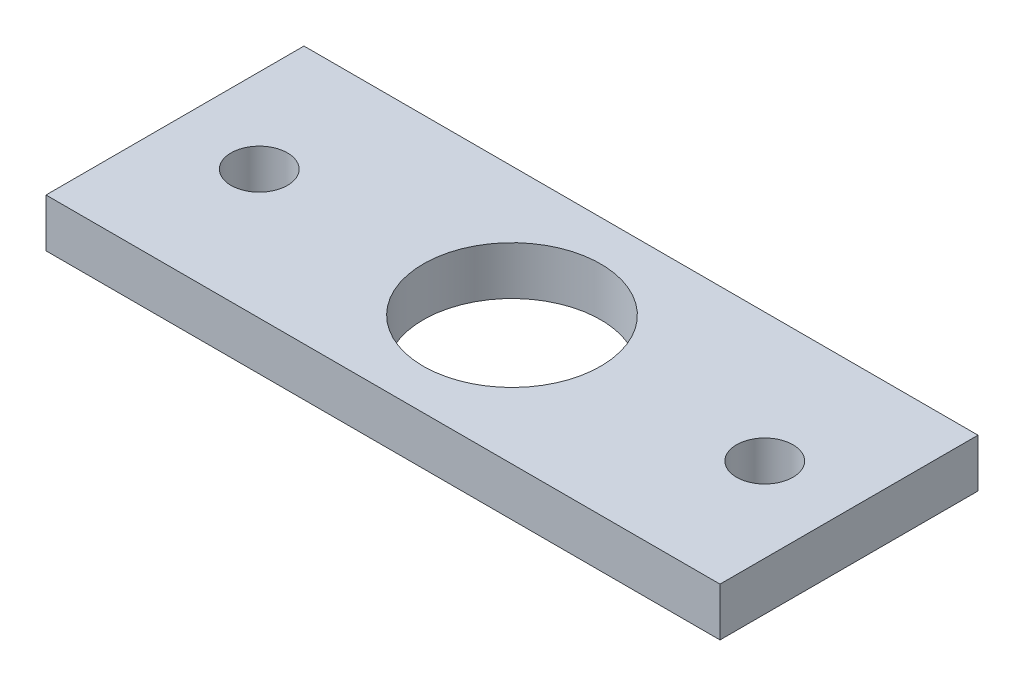
from build123d import *

# Parameters (mm, degrees)
SKETCH1_W           = 41.8
SKETCH1_H           = 16
SKETCH1_R           = 1.75
SKETCH1_R_2         = 5.5
BOSS_EXTRUDE1_DEPTH = 3


with BuildPart() as part:
    # Sketch1 → Boss-Extrude1 (new body)
    with BuildSketch(Plane(origin=(0, 0, 0), x_dir=(1, 0, 0), z_dir=(0, 1, 0))):
        Rectangle(SKETCH1_W, SKETCH1_H)
        with Locations((-15.675, 0)):
            Circle(SKETCH1_R, mode=Mode.SUBTRACT)
        with Locations((15.675, 0)):
            Circle(SKETCH1_R, mode=Mode.SUBTRACT)
        Circle(SKETCH1_R_2, mode=Mode.SUBTRACT)
    extrude(amount=BOSS_EXTRUDE1_DEPTH)


solid = part.part
